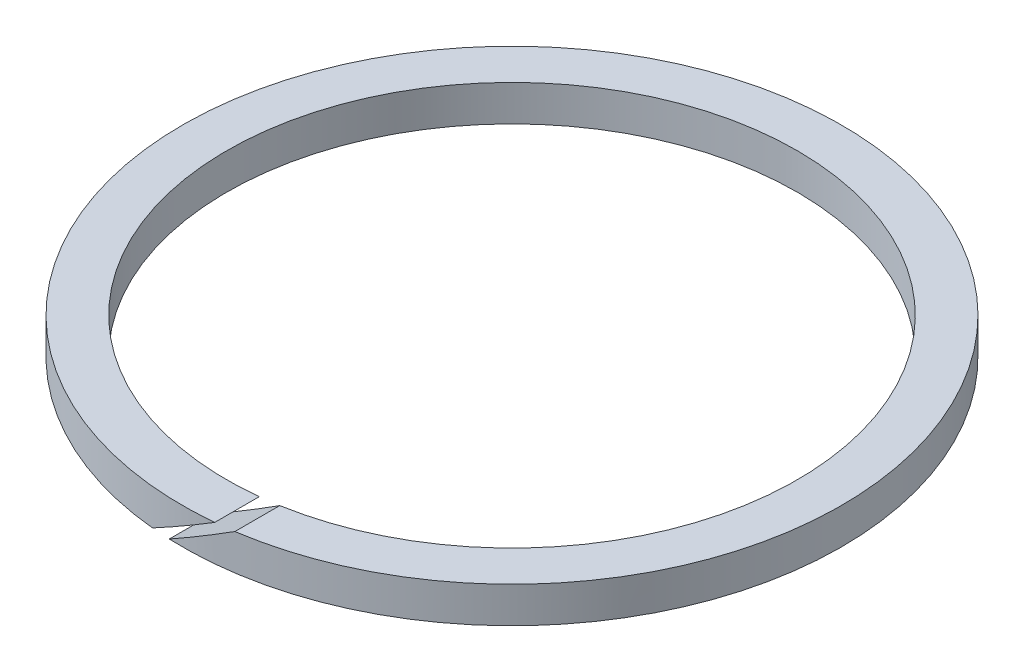
from build123d import *

# Parameters (mm, degrees)
SKETCH1_R               = 27.5
SKETCH1_R_2             = 23.8
BOSS_EXTRUDE1_DEPTH     = 3
CUT_EXTRUDE1_REACH      = 63.565
CUT_EXTRUDE1_END_RADIUS = 23.8


with BuildPart() as part:
    # Sketch1 → Boss-Extrude1 (new body)
    with BuildSketch(Plane(origin=(0, 0, 0), x_dir=(1, 0, 0), z_dir=(0, 1, 0))):
        with Locations(Location((0, 0, 0), (0, 0, 270))):
            Circle(SKETCH1_R)
        with Locations(Location((0, 0, 0), (0, 0, 270))):
            Circle(SKETCH1_R_2, mode=Mode.SUBTRACT)
    extrude(amount=BOSS_EXTRUDE1_DEPTH)

    # Cut-Extrude1: up to this cylinder (the profile starts outside it)
    cut_extrude1_end = Plane(origin=(0, 1.5, 0), z_dir=(0, -1, 0)) * Cylinder(CUT_EXTRUDE1_END_RADIUS, 175.73, mode=Mode.PRIVATE)
    # Sketch2 → Cut-Extrude1 (cut, up to the surface)
    with BuildSketch(Plane.XY.offset(27.5), mode=Mode.PRIVATE) as cut_extrude1_sk1:
        Polygon((-2.627763182, 0), (2.56838924, 3), (4.06838924, 3), (-1.127763182, 0), align=None)
    cut_extrude1_tool1 = extrude(cut_extrude1_sk1.sketch, amount=-CUT_EXTRUDE1_REACH, mode=Mode.PRIVATE) - cut_extrude1_end
    add(cut_extrude1_tool1.solids().sort_by_distance((0.720313, 1.5, 27.5))[0], mode=Mode.SUBTRACT)


solid = part.part
